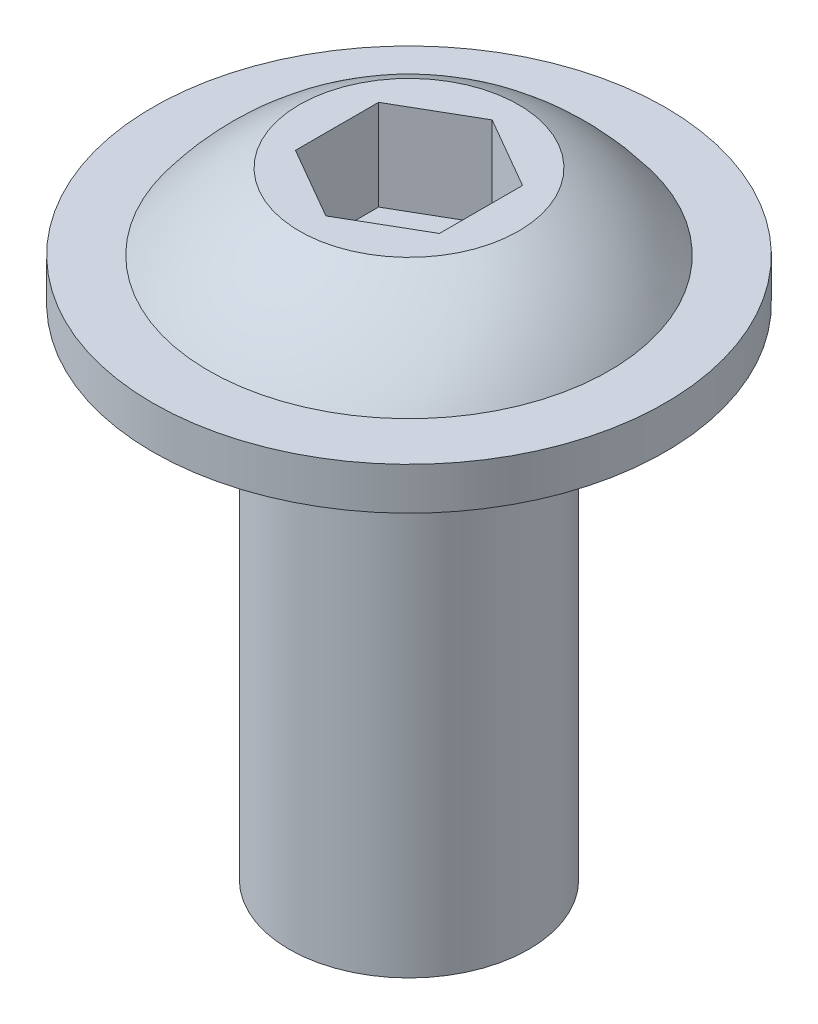
from build123d import *

# Parameters (mm, degrees)
SKETCH1_R           = 3.96875
BOSS_EXTRUDE1_DEPTH = 16.5
SKETCH2_R           = 8.475
BOSS_EXTRUDE2_DEPTH = 1.4
CUT_EXTRUDE1_DEPTH  = 3


with BuildPart() as part:
    # Sketch1 → Boss-Extrude1 (new body)
    with BuildSketch(Plane(origin=(0, 0, 0), x_dir=(1, 0, 0), z_dir=(0, 1, 0))):
        Circle(SKETCH1_R)
    extrude(amount=BOSS_EXTRUDE1_DEPTH)

    # Sketch2 → Boss-Extrude2 (add)
    with BuildSketch(Plane(origin=(0, 16.5, 0), x_dir=(1, 0, 0), z_dir=(0, 1, 0))):
        Circle(SKETCH2_R)
    extrude(amount=BOSS_EXTRUDE2_DEPTH)

    # Sketch3 → Revolve2 (revolve)
    with BuildSketch(Plane.XY):
        with BuildLine():
            Line((-3.625, 20.4), (0, 20.4))
            Line((0, 20.4), (0, 17.9))
            Line((0, 17.9), (-6.625, 17.9))
            ThreePointArc((-6.625, 17.9), (-5.275236962, 19.330284354), (-3.625, 20.4))
        make_face()
    revolve(axis=Axis((0, 20.4, 0), (0, -1, 0)))

    # Sketch4 → Cut-Extrude1 (cut)
    with BuildSketch(Plane(origin=(0, 20.4, 0), x_dir=(1, 0, 0), z_dir=(0, 1, 0))):
        Polygon((-2.38125, 1.374815329), (-2.38125, -1.374815329), (0, -2.749630657), (2.38125, -1.374815329), (2.38125, 1.374815329), (0, 2.749630657), align=None)
    extrude(amount=-CUT_EXTRUDE1_DEPTH, mode=Mode.SUBTRACT)


solid = part.part
